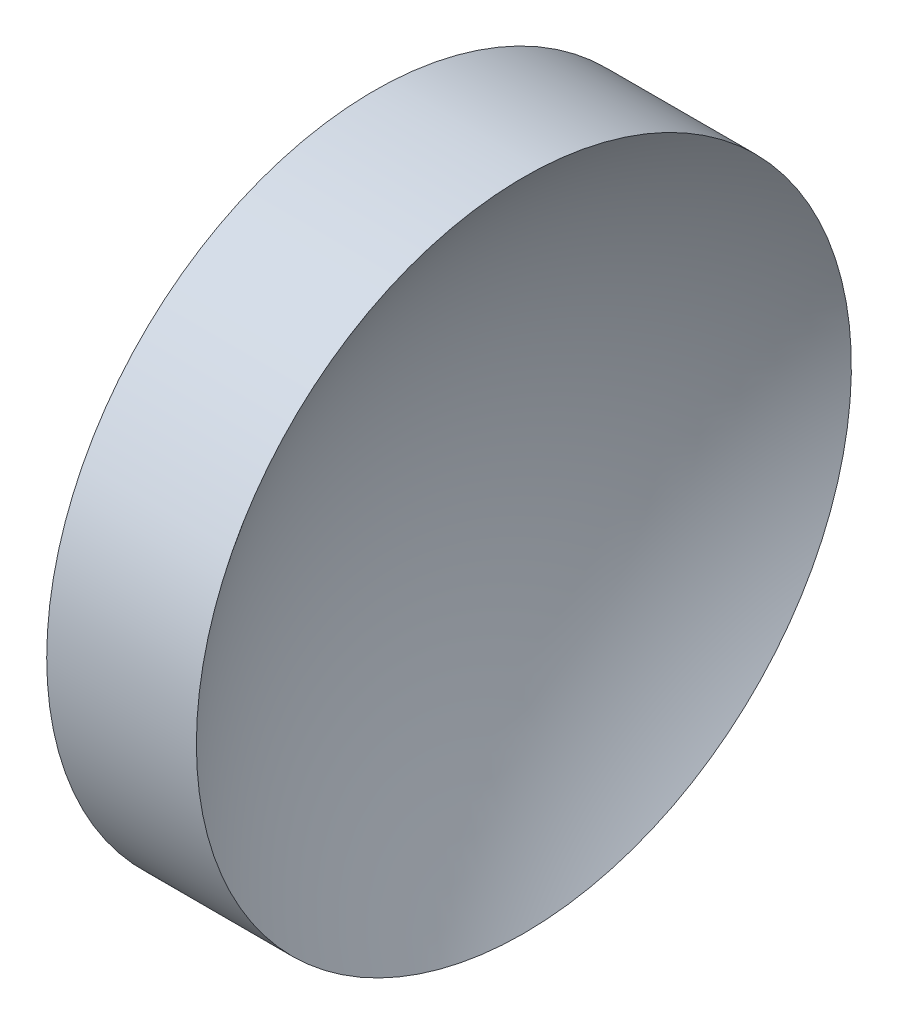
from build123d import *


with BuildPart() as part:
    # 草图1 → 旋转1 (revolve)
    with BuildSketch(Plane.XY, mode=Mode.PRIVATE) as revolve_1_sk:
        with BuildLine():
            Line((113.739437135, 65.155630457), (113.739437135, 90.155630457))
            Line((113.739437135, 90.155630457), (125.165587345, 90.155630457))
            ThreePointArc((125.165587345, 90.155630457), (118.902625842, 78.346536485), (116.739437135, 65.155630457))
            Line((116.739437135, 65.155630457), (113.739437135, 65.155630457))
        make_face()
    revolve(revolve_1_sk.sketch.rotate(Axis((105.621837124, 65.155630457, 0), (1, 0, 0)), 180), axis=Axis((105.621837124, 65.155630457, 0), (1, 0, 0)))  # turned: the seam where the file's is


solid = part.part
